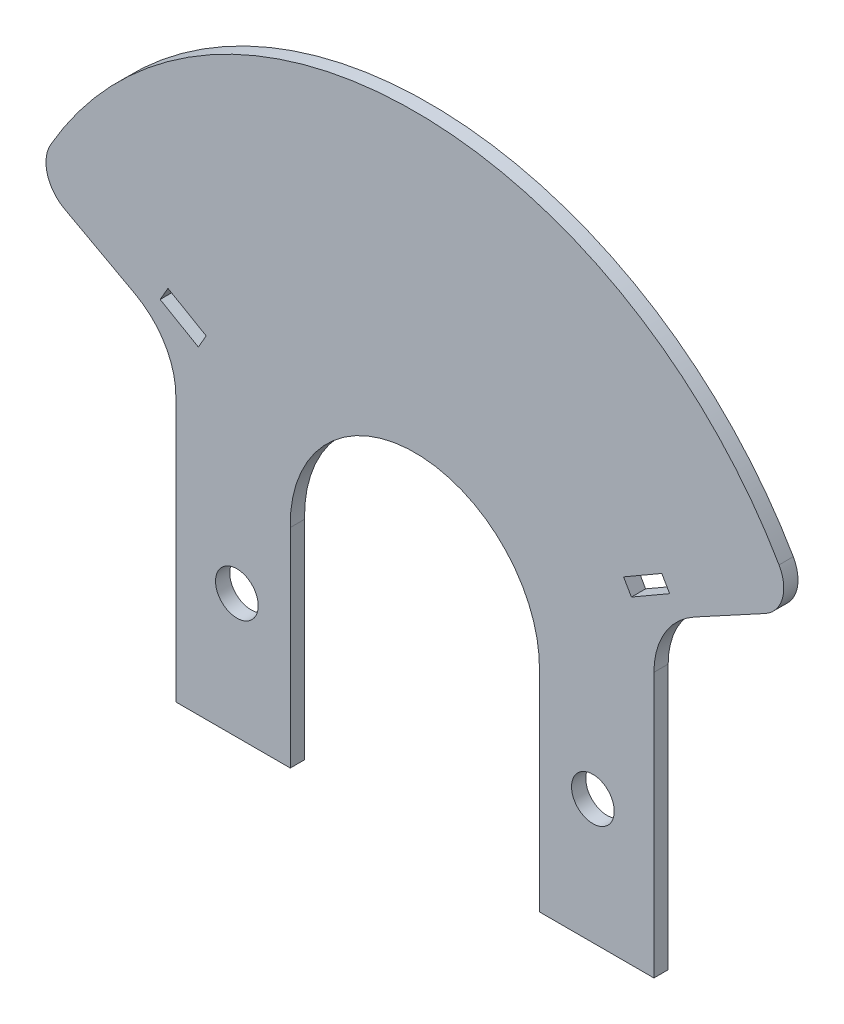
from build123d import *

# Parameters (mm, degrees)
SKETCH1_R           = 3
BOSS_EXTRUDE1_DEPTH = 2
FILLET1_R           = 5


with BuildPart() as part:
    # Sketch1 → Boss-Extrude1 (new body)
    with BuildSketch(Plane.XY):
        with BuildLine():
            Line((-17.5, -29.9861237), (-33.570384709, -29.9861237))
            Line((-33.570384709, -29.9861237), (-33.570384709, 7.191652864))
            ThreePointArc((-33.570384709, 7.191652864), (-35.102603086, 12.763157514), (-39.268321068, 16.767673829))
            Line((-39.268321068, 16.767673829), (-53.500564058, 24.492870138))
            ThreePointArc((-53.500564058, 24.492870138), (0, 58.627853025), (53.500564058, 24.492870138))
            Line((53.500564058, 24.492870138), (39.268321068, 16.767673829))
            ThreePointArc((39.268321068, 16.767673829), (35.102603086, 12.763157514), (33.570384709, 7.191652864))
            Line((33.570384709, 7.191652864), (33.570384709, -29.9861237))
            Line((33.570384709, -29.9861237), (17.5, -29.9861237))
            Line((17.5, -29.9861237), (17.5, -0.731973174))
            ThreePointArc((17.5, -0.731973174), (0, 17.137840029), (-17.5, -0.731973174))
            Line((-17.5, -0.731973174), (-17.5, -29.9861237))
        make_face()
        with Locations((-25, -12.5)):
            Circle(SKETCH1_R, mode=Mode.SUBTRACT)
        with Locations((25, -12.5)):
            Circle(SKETCH1_R, mode=Mode.SUBTRACT)
        Polygon((-35.777618692, 17.865360065), (-30.408261188, 14.765360065), (-29.308261188, 16.670615954), (-34.677618692, 19.770615954), align=None, mode=Mode.SUBTRACT)
        Polygon((30.408261188, 14.765360065), (29.308261188, 16.670615954), (34.677618692, 19.770615954), (35.777618692, 17.865360065), align=None, mode=Mode.SUBTRACT)
    extrude(amount=BOSS_EXTRUDE1_DEPTH)

    # Fillet1
    fillet1_edges = [part.edges().sort_by_distance(p)[0] for p in [
        (-53.500564058, 24.492870138, 1),
        (53.500564058, 24.492870138, 1),
    ]]
    fillet(fillet1_edges, radius=FILLET1_R)


solid = part.part
